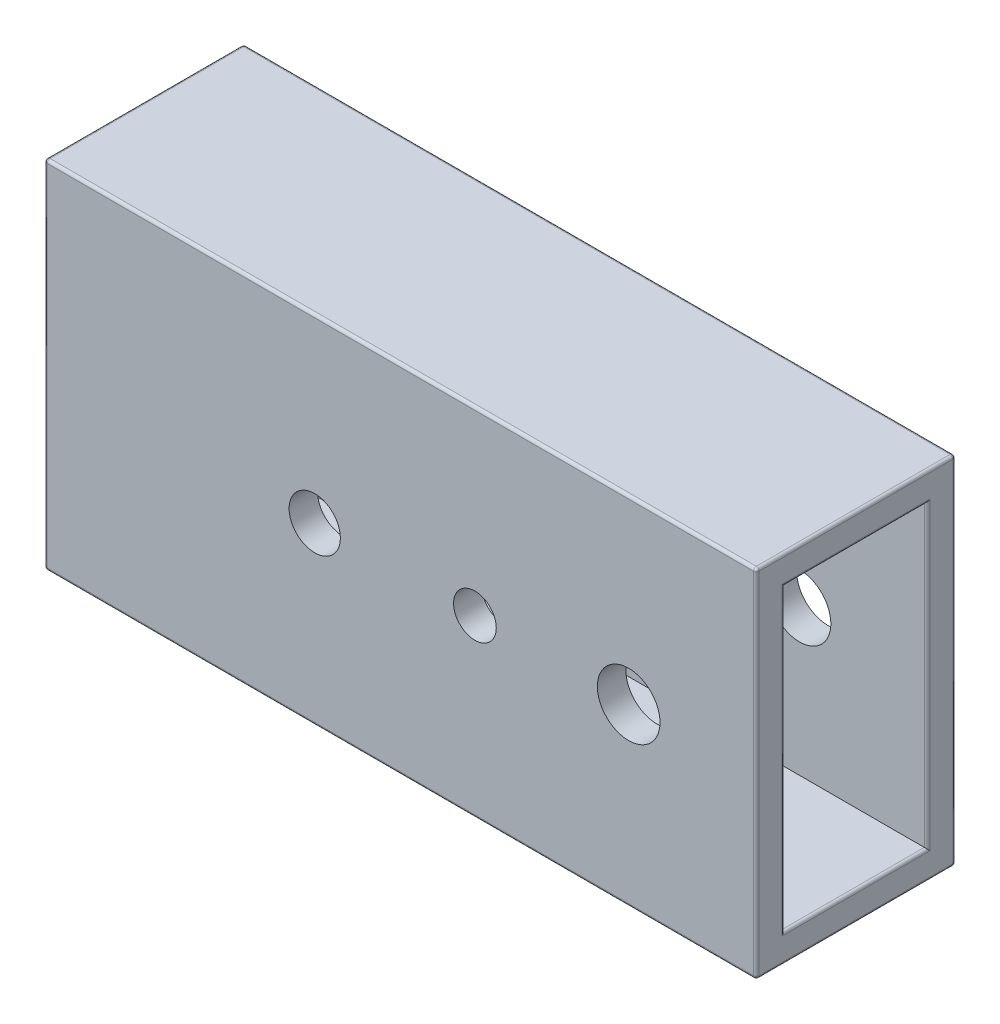
from build123d import *

# Parameters (mm, degrees)
SKETCH1_W           = 250
SKETCH1_H           = 125
BOSS_EXTRUDE1_DEPTH = 35
SHELL1_T            = -10
SKETCH2_R           = 11
SKETCH2_R_2         = 7.5
SKETCH2_R_3         = 9
CUT_EXTRUDE1_DEPTH  = 70
FILLET1_R           = 1


with BuildPart() as part:
    # Sketch1 → Boss-Extrude1 (new body, symmetric)
    with BuildSketch(Plane.XY):
        with Locations((-130.188284519, 30.930962343)):
            Rectangle(SKETCH1_W, SKETCH1_H)
    extrude(amount=BOSS_EXTRUDE1_DEPTH, both=True)

    # Shell1
    shell1_openings = [part.faces().sort_by_distance(p)[0] for p in [
        (-5.188284519, 30.930962343, 0),
    ]]
    offset(amount=SHELL1_T, openings=shell1_openings, kind=Kind.INTERSECTION)

    # Sketch2 → Cut-Extrude1 (cut)
    with BuildSketch(Plane.XY.offset(35)):
        with Locations((-50, 30)):
            Circle(SKETCH2_R)
        with Locations((-104, 30)):
            Circle(SKETCH2_R_2)
        with Locations((-160.25, 30)):
            Circle(SKETCH2_R_3)
    extrude(amount=-CUT_EXTRUDE1_DEPTH, mode=Mode.SUBTRACT)

    # Fillet1
    fillet1_edges = [part.edges().sort_by_distance(p)[0] for p in [
        (-255.188284519, 30.930962343, 35),
        (-5.188284519, 30.930962343, -25),
        (-5.188284519, -21.569037657, 0),
        (-5.188284519, 83.430962343, 0),
        (-130.188284519, -31.569037657, 35),
        (-5.188284519, 30.930962343, 25),
        (-5.188284519, 30.930962343, 35),
        (-130.188284519, -31.569037657, -35),
        (-255.188284519, 30.930962343, -35),
        (-130.188284519, 93.430962343, -35),
        (-5.188284519, 30.930962343, -35),
        (-5.188284519, -31.569037657, 0),
        (-255.188284519, -31.569037657, 0),
        (-255.188284519, 93.430962343, 0),
        (-5.188284519, 93.430962343, 0),
        (-130.188284519, 93.430962343, 35),
    ]]
    fillet(fillet1_edges, radius=FILLET1_R)


solid = part.part
